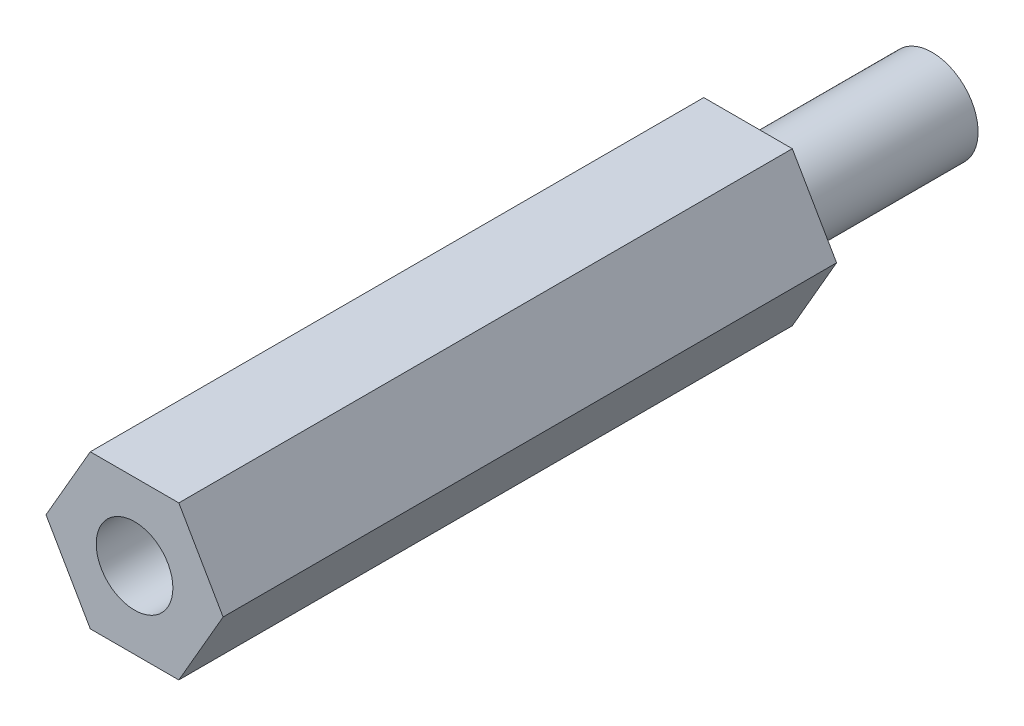
from build123d import *

# Parameters (mm, degrees)
EXTRUDE_1_DEPTH = 20
SKETCH_4_R      = 1.5
EXTRUDE_2_DEPTH = 6
M3X0_5_1_D      = 2.5
M3X0_5_1_DEPTH  = 7.5
M3X0_5_1_TIP    = 0.751075774


with BuildPart() as part:
    # 草圖1 → 填料-伸長1 (new body)
    with BuildSketch(Plane.XY):
        Polygon((-1.443375673, 2.5), (-2.886751346, 0), (-1.443375673, -2.5), (1.443375673, -2.5), (2.886751346, 0), (1.443375673, 2.5), align=None)
    extrude(amount=EXTRUDE_1_DEPTH)

    # 草圖4 → 填料-伸長2 (add)
    with BuildSketch(Plane(origin=(0, 0, 0), x_dir=(-1, 0, 0), z_dir=(0, 0, -1))):
        Circle(SKETCH_4_R)
    extrude(amount=EXTRUDE_2_DEPTH)

    # M3x0.5 螺紋孔1
    with Locations(Plane.XY.offset(20)):
        with Locations((0, 0)):
            Hole(M3X0_5_1_D / 2, depth=M3X0_5_1_DEPTH)
            with Locations((0, 0, -(M3X0_5_1_DEPTH + M3X0_5_1_TIP / 2))):  # 118° drill point
                Cone(0, M3X0_5_1_D / 2, M3X0_5_1_TIP, mode=Mode.SUBTRACT)


solid = part.part
